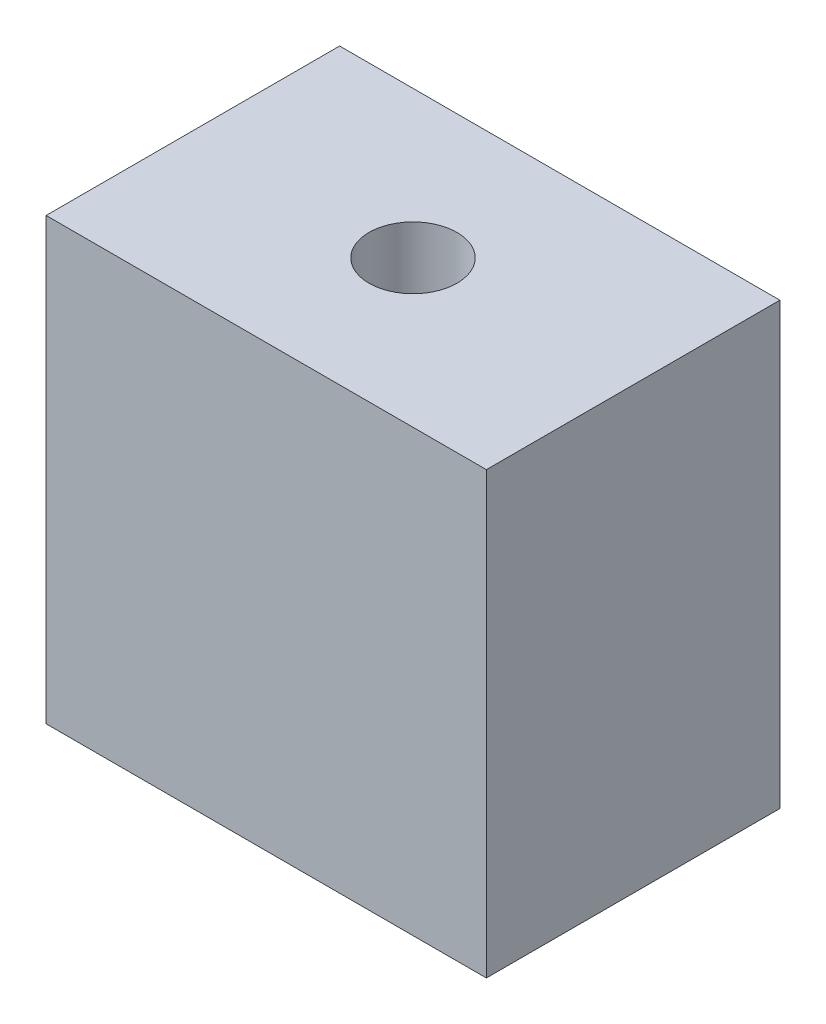
from build123d import *

# Parameters (mm, degrees)
SKETCH1_W           = 38.1
SKETCH1_H           = 25.4
SKETCH1_R           = 3.81
BOSS_EXTRUDE1_DEPTH = 38.1


with BuildPart() as part:
    # Sketch1 → Boss-Extrude1 (new body)
    with BuildSketch(Plane(origin=(0, 0, 0), x_dir=(1, 0, 0), z_dir=(0, 1, 0))):
        with Locations((-19.05, 12.7)):
            Rectangle(SKETCH1_W, SKETCH1_H)
        with Locations((-19.05, 12.7)):
            Circle(SKETCH1_R, mode=Mode.SUBTRACT)
    extrude(amount=BOSS_EXTRUDE1_DEPTH)


solid = part.part
